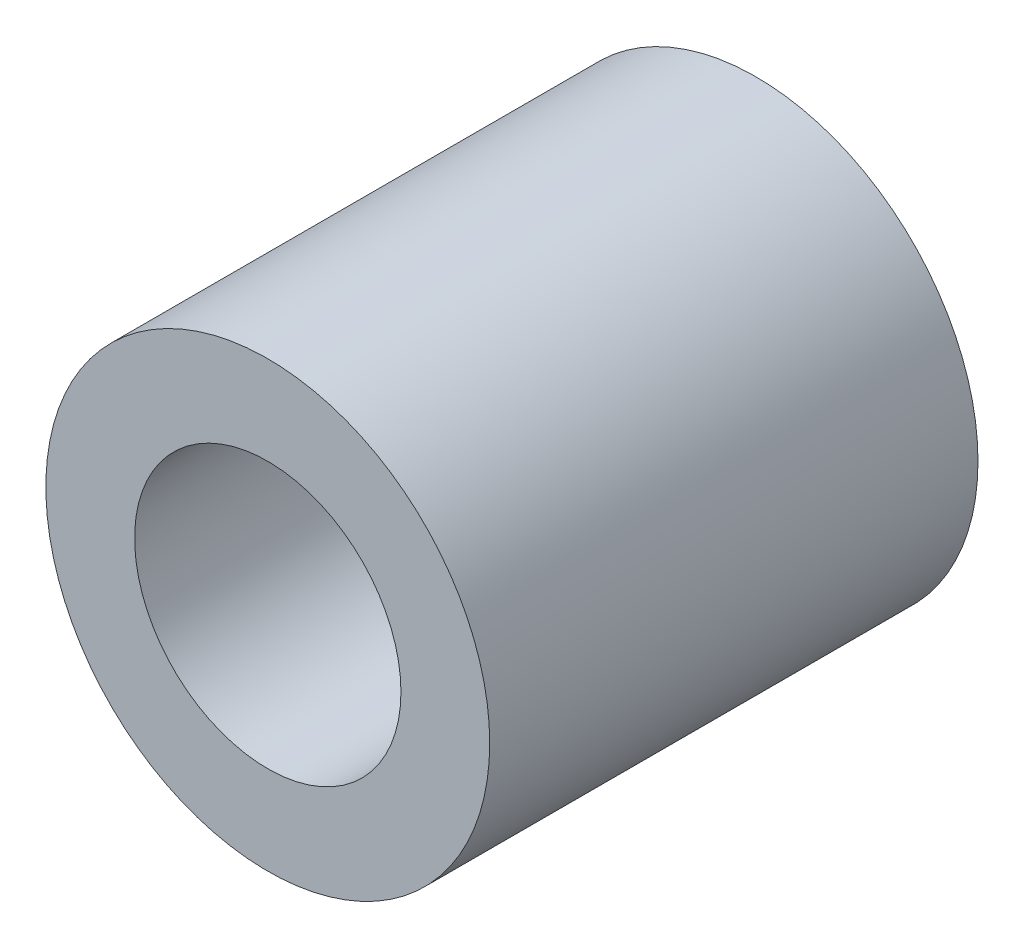
from build123d import *

# Parameters (mm, degrees)
SKETCH2_R           = 2.5
SKETCH2_R_2         = 1.5
BOSS_EXTRUDE1_DEPTH = 5.5


with BuildPart() as part:
    # Sketch2 → Boss-Extrude1 (new body)
    with BuildSketch(Plane.XY):
        Circle(SKETCH2_R)
        Circle(SKETCH2_R_2, mode=Mode.SUBTRACT)
    extrude(amount=BOSS_EXTRUDE1_DEPTH)


solid = part.part
